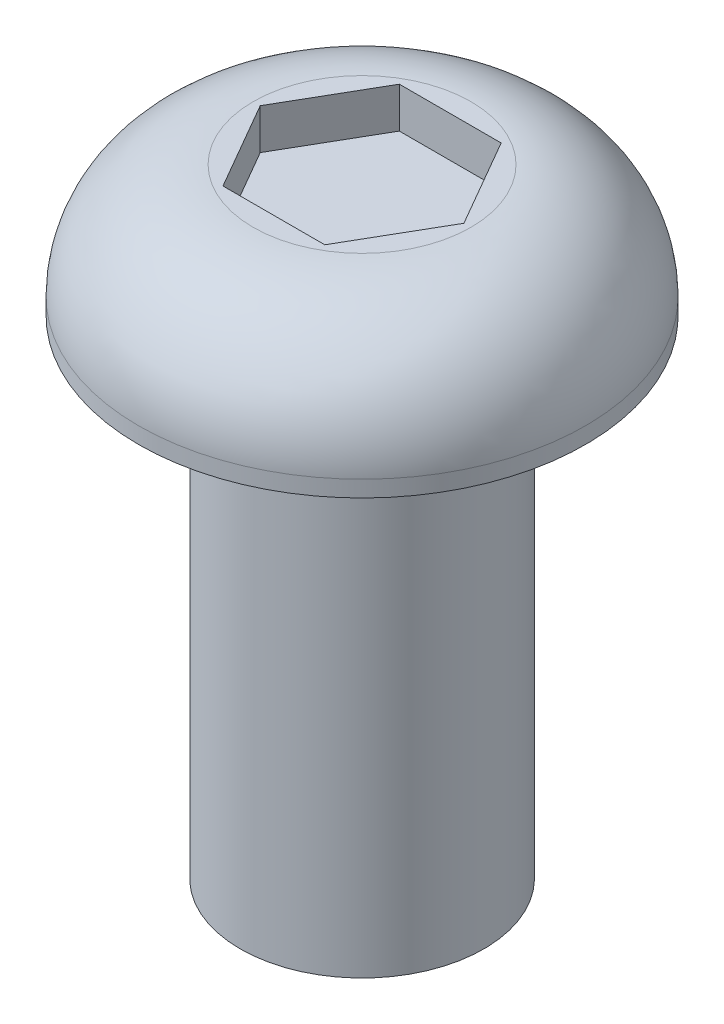
from build123d import *

# Parameters (mm, degrees)
CUT_EXTRUDE1_DEPTH = 0.5


with BuildPart() as part:
    # Sketch1 → Revolve1 (revolve)
    with BuildSketch(Plane.XY):
        with BuildLine():
            Line((0, 1.61), (1.34, 1.61))
            ThreePointArc((1.34, 1.61), (2.337020561, 1.197020561), (2.75, 0.2))
            Line((2.75, 0.2), (2.75, 0))
            Line((2.75, 0), (1.5, 0))
            Line((1.5, 0), (1.5, -6))
            Line((1.5, -6), (0, -6))
            Line((0, -6), (0, 1.61))
        make_face()
    revolve(axis=Axis((0, 9.083769969, 0), (0, -1, 0)))

    # Sketch2 → Cut-Extrude1 (cut)
    with BuildSketch(Plane(origin=(0, 1.61, 0), x_dir=(1, 0, 0), z_dir=(0, 1, 0))):
        Polygon((0.62654248, 1.085203409), (-0.62654248, 1.085203409), (-1.253084961, 0), (-0.62654248, -1.085203409), (0.62654248, -1.085203409), (1.253084961, 0), align=None)
    extrude(amount=-CUT_EXTRUDE1_DEPTH, mode=Mode.SUBTRACT)


solid = part.part
